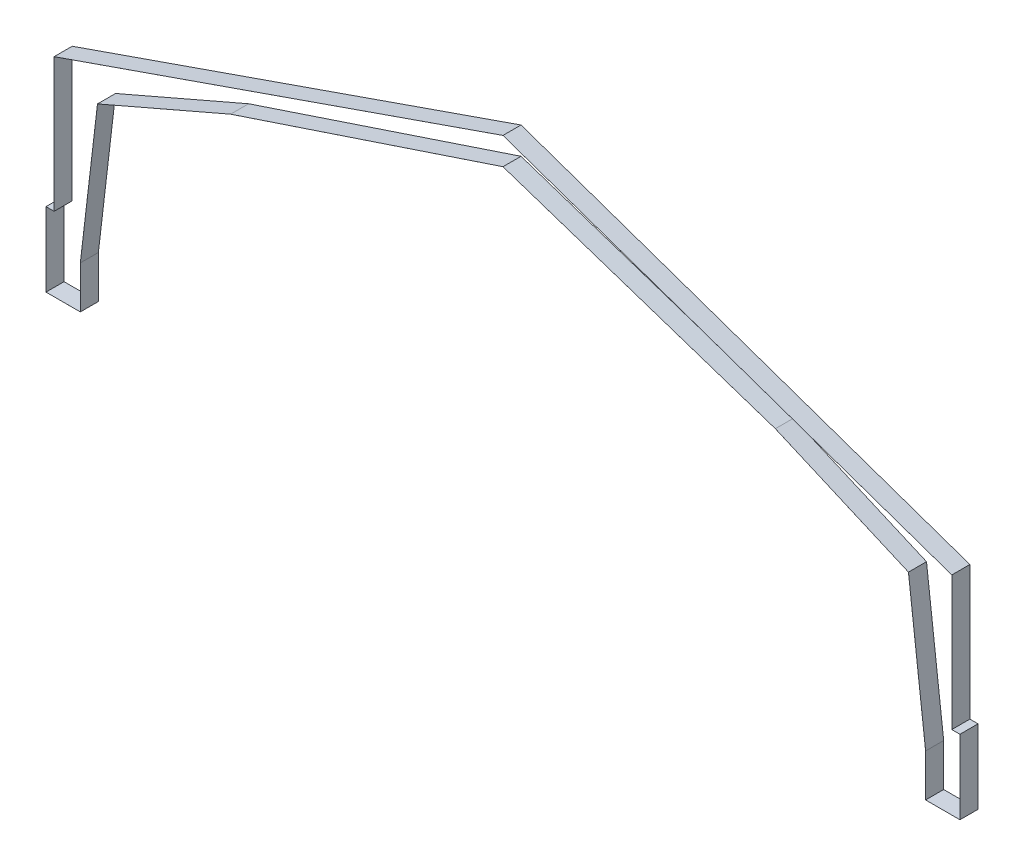
from build123d import *

# Parameters (mm, degrees)
EXTRUIR_L_MINA1_DEPTH = 254


with BuildPart() as part:
    # Croquis1 → Extruir-Lámina1 (new body, symmetric)
    with BuildSketch(Plane.XY):
        Polygon((20513.007562206, 6929.762411967), (24256.764775023, 5308.425074033), (24739.346, 1193.785155811), (24739.346, -0.254), (25705.054, -0.254), (25705.054, 2083.054), (25476.454, 2083.054), (25476.454, 5849.677222807), (12852.4, 10243.072942272), (228.346, 5849.677222807), (228.346, 2083.054), (-0.254, 2083.054), (-0.254, -0.254), (965.454, -0.254), (965.454, 1193.785155811), (1448.035224977, 5308.425074033), (5191.792437794, 6929.762411967), (12852.4, 9480.536289437), align=None)
        Polygon((20513.098327776, 6929.999900065), (24257, 5308.6), (24739.6, 1193.8), (24739.6, 0), (25704.8, 0), (25704.8, 2082.8), (25476.2, 2082.8), (25476.2, 5849.49667706), (12852.4, 10242.804), (228.6, 5849.49667706), (228.6, 2082.8), (0, 2082.8), (0, 0), (965.2, 0), (965.2, 1193.8), (1447.8, 5308.6), (5191.701672224, 6929.999900065), (12852.4, 9480.804), align=None, mode=Mode.SUBTRACT)
    extrude(amount=EXTRUIR_L_MINA1_DEPTH, both=True)


solid = part.part
